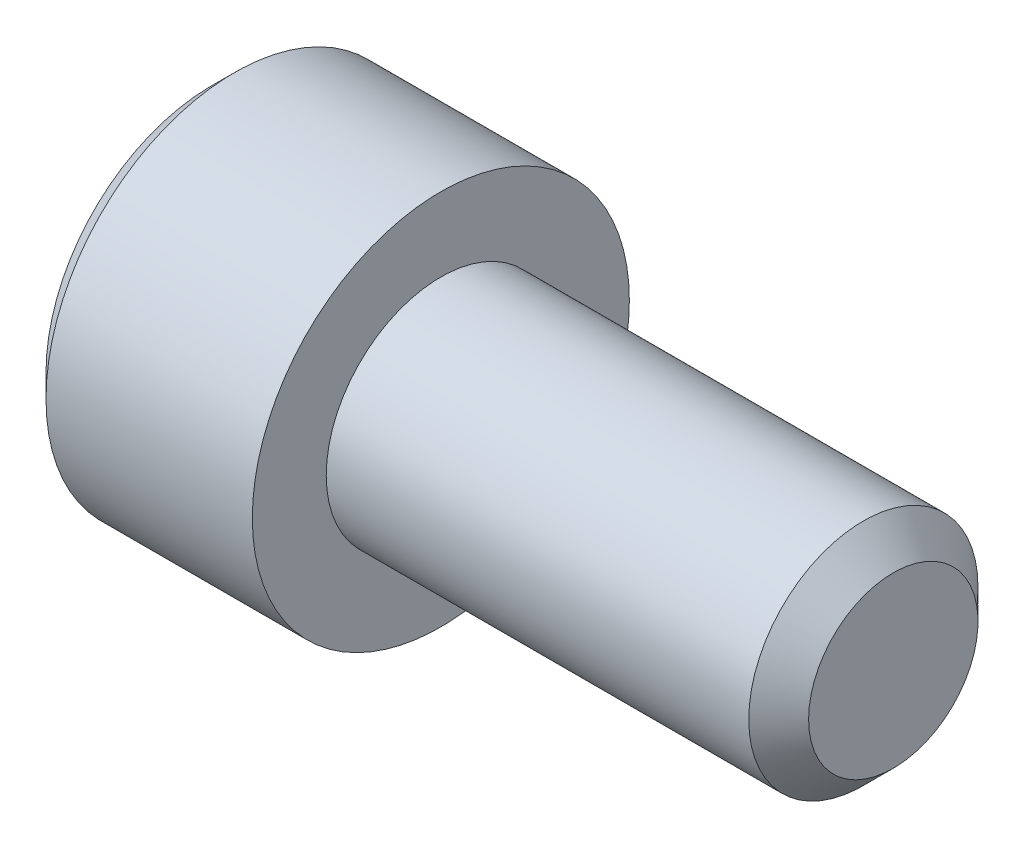
from build123d import *

# Parameters (mm, degrees)
HEX_2_DEPTH = 2.286


with BuildPart() as part:
    # BodySke → Base-Revolve (revolve)
    with BuildSketch(Plane.XY, mode=Mode.PRIVATE) as base_revolve_sk:
        Polygon((0, 0), (0, 3.48615), (0.4826, 3.96875), (4.826, 3.96875), (4.826, 2.413), (13.72108, 2.413), (14.351, 1.78308), (14.351, 0), align=None)
    revolve(base_revolve_sk.sketch.rotate(Axis((-31.75, 0, 0), (1, 0, 0)), 90), axis=Axis((-31.75, 0, 0), (1, 0, 0)))  # turned: the seam where the file's is

    # Sketch2 → Hex-PreBroach (revolve, cut)
    with BuildSketch(Plane.XY, mode=Mode.PRIVATE) as hex_prebroach_sk:
        Polygon((0, 1.98501), (2.286, 1.98501), (3.432046058, 0), (0, 0), align=None)
    revolve(hex_prebroach_sk.sketch.rotate(Axis((0, 0, 0), (1, 0, 0)), 90), axis=Axis((0, 0, 0), (1, 0, 0)), mode=Mode.SUBTRACT)  # turned: the seam where the file's is

    # Sketch3 → Hex 2 (cut)
    with BuildSketch(Plane(origin=(0, 0, 0), x_dir=(0, 0.5, 0.866025404), z_dir=(-1, 0, 0))):
        Polygon((1.146046058, 1.98501), (-1.146046058, 1.98501), (-2.292092116, 0), (-1.146046058, -1.98501), (1.146046058, -1.98501), (2.292092116, 0), align=None)
    extrude(amount=-HEX_2_DEPTH, mode=Mode.SUBTRACT)


solid = part.part
